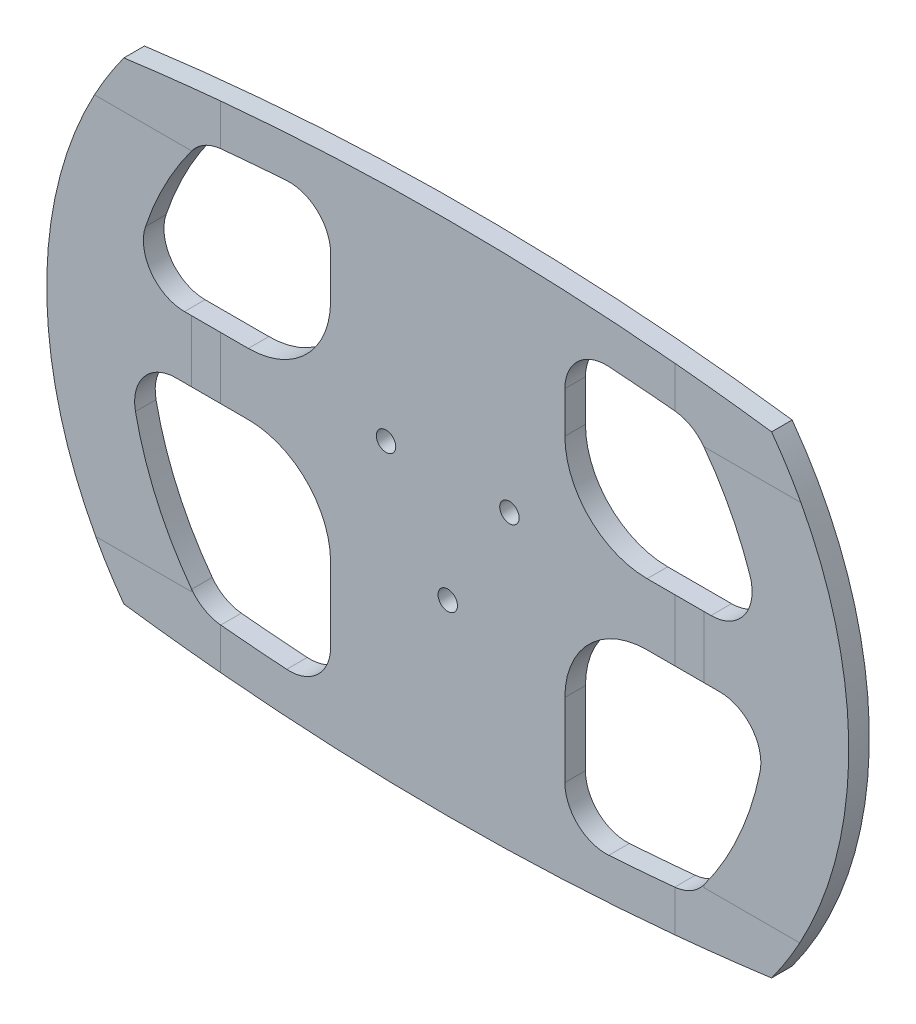
from build123d import *

# Parameters (mm, degrees)
BOSS_EXTRUDE1_DEPTH = 6.35
CUT_EXTRUDE1_DEPTH  = 7.35
SKETCH4_R           = 3
CUT_EXTRUDE2_DEPTH  = 7.35


with BuildPart() as part:
    # Sketch2 → Boss-Extrude1 (new body)
    with BuildSketch(Plane.XY):
        with BuildLine():
            ThreePointArc((-100, 73.02486306), (0, 79.721425695), (100, 73.02486306))
            ThreePointArc((100, 73.02486306), (123.825, 0), (100, -73.02486306))
            ThreePointArc((100, -73.02486306), (0, -79.721425695), (-100, -73.02486306))
            ThreePointArc((-100, -73.02486306), (-123.825, 0), (-100, 73.02486306))
        make_face()
    extrude(amount=BOSS_EXTRUDE1_DEPTH)

    # Sketch3 → Cut-Extrude1 (cut, through all)
    with BuildSketch(Plane.XY.offset(6.35)):
        with BuildLine():
            Line((-61.572799723, 14.542440806), (-81.281148146, 14.542440806))
            ThreePointArc((-81.281148146, 14.542440806), (-91.5900314, 19.825101253), (-93.322799723, 31.278357963))
            ThreePointArc((-93.322799723, 31.278357963), (-87.27608067, 45.501278749), (-79.077484693, 58.602321112))
            ThreePointArc((-79.077484693, 58.602321112), (-75.119328128, 62.098990903), (-70.081085695, 63.683230851))
            ThreePointArc((-70.081085695, 63.683230851), (-59.910981492, 64.583293189), (-49.729388954, 65.342440806))
            ThreePointArc((-49.729388954, 65.342440806), (-40.200680121, 61.949526114), (-36.172799723, 52.671361338))
            Line((-36.172799723, 52.671361338), (-36.172799723, 39.942440806))
            ThreePointArc((-36.172799723, 39.942440806), (-43.612287481, 21.981928564), (-61.572799723, 14.542440806))
        make_face()
        with BuildLine():
            Line((36.172799723, -29.907559194), (36.172799723, -52.671361338))
            ThreePointArc((36.172799723, -52.671361338), (40.200680121, -61.949526114), (49.729388954, -65.342440806))
            ThreePointArc((49.729388954, -65.342440806), (59.910981492, -64.583293189), (70.081085695, -63.683230851))
            ThreePointArc((70.081085695, -63.683230851), (75.119328128, -62.098990903), (79.077484693, -58.602321112))
            ThreePointArc((79.077484693, -58.602321112), (89.8734441, -40.12785405), (96.421721635, -19.756827222))
            ThreePointArc((96.421721635, -19.756827222), (93.820577654, -9.179038283), (83.980209166, -4.507559194))
            Line((83.980209166, -4.507559194), (61.572799723, -4.507559194))
            ThreePointArc((61.572799723, -4.507559194), (43.612287481, -11.947046951), (36.172799723, -29.907559194))
        make_face()
        with BuildLine():
            Line((-61.572799723, -4.507559194), (-83.980209166, -4.507559194))
            ThreePointArc((-83.980209166, -4.507559194), (-93.820577654, -9.179038283), (-96.421721635, -19.756827222))
            ThreePointArc((-96.421721635, -19.756827222), (-89.8734441, -40.12785405), (-79.077484693, -58.602321112))
            ThreePointArc((-79.077484693, -58.602321112), (-75.119328128, -62.098990903), (-70.081085695, -63.683230851))
            ThreePointArc((-70.081085695, -63.683230851), (-59.910981492, -64.583293189), (-49.729388954, -65.342440806))
            ThreePointArc((-49.729388954, -65.342440806), (-40.200680121, -61.949526114), (-36.172799723, -52.671361338))
            Line((-36.172799723, -52.671361338), (-36.172799723, -29.907559194))
            ThreePointArc((-36.172799723, -29.907559194), (-43.612287481, -11.947046951), (-61.572799723, -4.507559194))
        make_face()
        with BuildLine():
            Line((36.172799723, 39.942440806), (36.172799723, 52.671361338))
            ThreePointArc((36.172799723, 52.671361338), (40.200680121, 61.949526114), (49.729388954, 65.342440806))
            ThreePointArc((49.729388954, 65.342440806), (59.910981492, 64.583293189), (70.081085695, 63.683230851))
            ThreePointArc((70.081085695, 63.683230851), (75.119328128, 62.098990903), (79.077484693, 58.602321112))
            ThreePointArc((79.077484693, 58.602321112), (87.27608067, 45.501278749), (93.322799723, 31.278357963))
            ThreePointArc((93.322799723, 31.278357963), (91.5900314, 19.825101253), (81.281148146, 14.542440806))
            Line((81.281148146, 14.542440806), (61.572799723, 14.542440806))
            ThreePointArc((61.572799723, 14.542440806), (43.612287481, 21.981928564), (36.172799723, 39.942440806))
        make_face()
    extrude(amount=-CUT_EXTRUDE1_DEPTH, mode=Mode.SUBTRACT)

    # Sketch4 → Cut-Extrude2 (cut, through all)
    with BuildSketch(Plane.XY.offset(6.35)):
        with Locations((-19.05, 10.998522628)):
            Circle(SKETCH4_R)
        with Locations((19.05, 10.998522628)):
            Circle(SKETCH4_R)
        with Locations((0, -21.997045256)):
            Circle(SKETCH4_R)
    extrude(amount=-CUT_EXTRUDE2_DEPTH, mode=Mode.SUBTRACT)


solid = part.part
